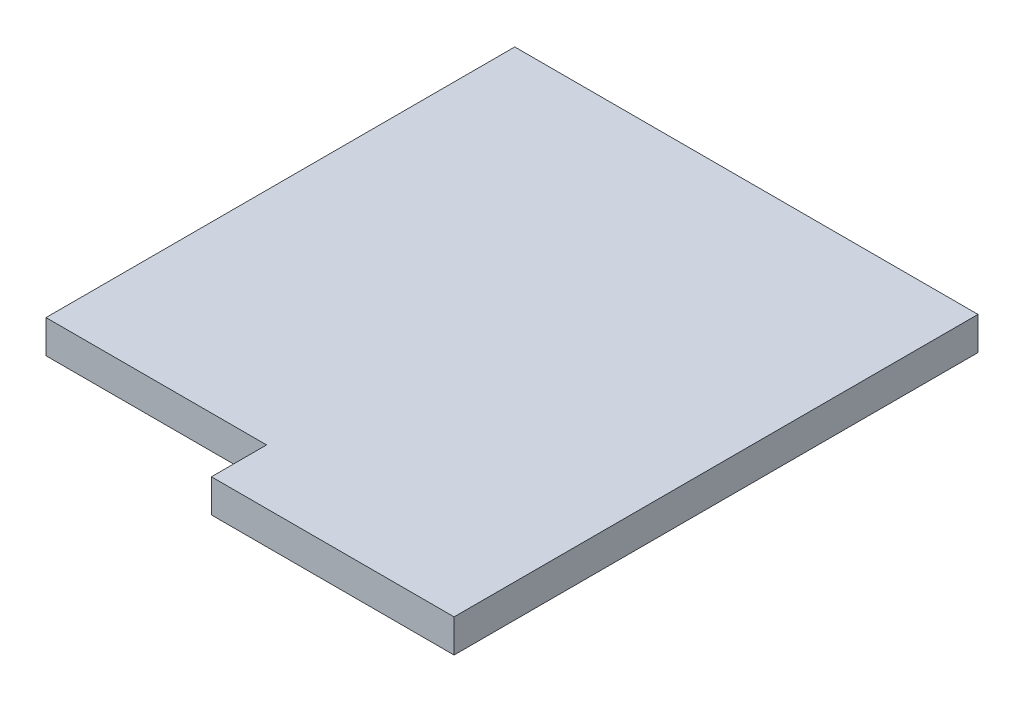
from build123d import *

# Parameters (mm, degrees)
SKETCH1_W           = 42
SKETCH1_H           = 47.5
BOSS_EXTRUDE1_DEPTH = 3
SKETCH2_W           = 20
SKETCH2_H           = 5
CUT_EXTRUDE1_DEPTH  = 5


with BuildPart() as part:
    # Sketch1 → Boss-Extrude1 (new body)
    with BuildSketch(Plane(origin=(0, 0, 0), x_dir=(1, 0, 0), z_dir=(0, 1, 0))):
        Rectangle(SKETCH1_W, SKETCH1_H)
    extrude(amount=BOSS_EXTRUDE1_DEPTH)

    # Sketch2 → Cut-Extrude1 (cut)
    with BuildSketch(Plane(origin=(0, 0, 0), x_dir=(1, 0, 0), z_dir=(0, 1, 0))):
        with Locations((-11, -21.25)):
            Rectangle(SKETCH2_W, SKETCH2_H)
    extrude(amount=CUT_EXTRUDE1_DEPTH, mode=Mode.SUBTRACT)


solid = part.part
